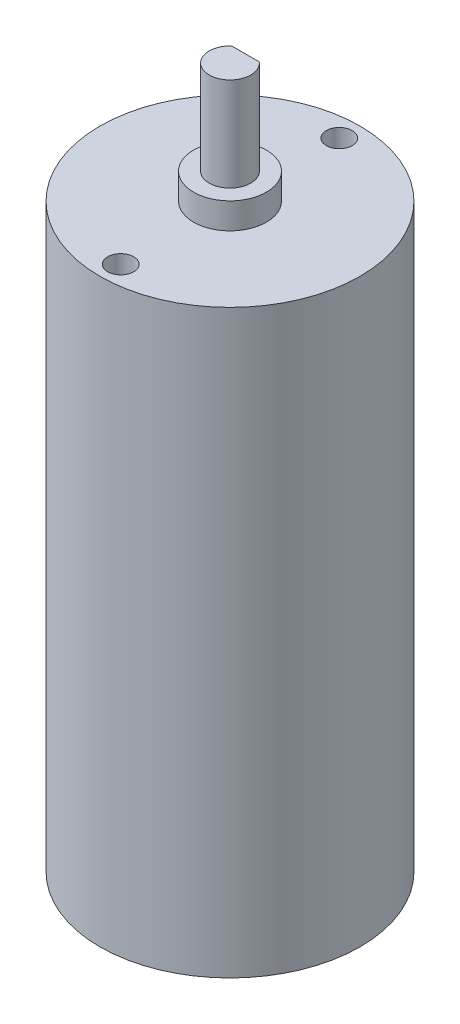
from build123d import *

# Parameters (mm, degrees)
SKETCH1_R           = 12.5
BOSS_EXTRUDE1_DEPTH = 55.8
SKETCH2_R           = 1.25
CUT_EXTRUDE1_DEPTH  = 5
SKETCH2_3_R         = 3.5
BOSS_EXTRUDE2_DEPTH = 2.5
BOSS_EXTRUDE3_DEPTH = 9


with BuildPart() as part:
    # Sketch1 → Boss-Extrude1 (new body)
    with BuildSketch(Plane(origin=(0, 0, 0), x_dir=(1, 0, 0), z_dir=(0, 1, 0))):
        Circle(SKETCH1_R)
    extrude(amount=BOSS_EXTRUDE1_DEPTH)

    # Sketch2 → Cut-Extrude1 (cut)
    with BuildSketch(Plane(origin=(0, 55.8, 0), x_dir=(1, 0, 0), z_dir=(0, 1, 0))):
        with Locations((0, 10.5)):
            Circle(SKETCH2_R)
        with Locations((0, -10.5)):
            Circle(SKETCH2_R)
    extrude(amount=-CUT_EXTRUDE1_DEPTH, mode=Mode.SUBTRACT)

    # Sketch2_3 → Boss-Extrude2 (add)
    with BuildSketch(Plane(origin=(0, 55.8, 0), x_dir=(1, 0, 0), z_dir=(0, 1, 0))):
        Circle(SKETCH2_3_R)
    extrude(amount=BOSS_EXTRUDE2_DEPTH)

    # Sketch3 → Boss-Extrude3 (add)
    with BuildSketch(Plane(origin=(0, 58.3, 0), x_dir=(1, 0, 0), z_dir=(0, 1, 0))):
        with BuildLine():
            Line((1.322875656, 1.5), (-1.322875656, 1.5))
            ThreePointArc((-1.322875656, 1.5), (-0.822875656, -1.822875656), (2, 0))
            ThreePointArc((2, 0), (1.822875656, 0.822875656), (1.322875656, 1.5))
        make_face()
    extrude(amount=BOSS_EXTRUDE3_DEPTH)


solid = part.part
